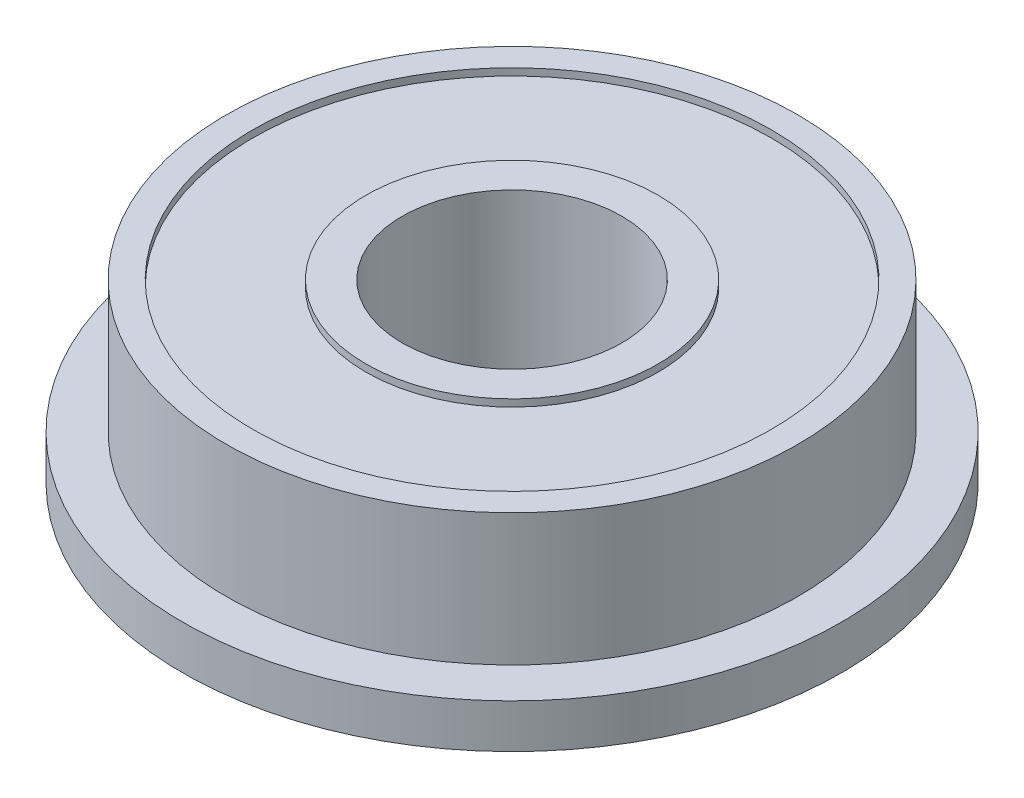
from build123d import *


with BuildPart() as part:
    # Sketch1 → Revolve1 (revolve)
    with BuildSketch(Plane.XY):
        Polygon((2.5, 0), (3.326219326, 0), (3.326219326, 0.162212443), (5.903572722, 0.162212443), (5.903572722, 0), (7.5, 0), (7.5, 1), (6.5, 1), (6.5, 4), (5.903572722, 4), (5.903572722, 3.837787557), (3.326219326, 3.837787557), (3.326219326, 4), (2.5, 4), align=None)
    revolve(axis=Axis((0, 0, 0), (0, 1, 0)))


solid = part.part
